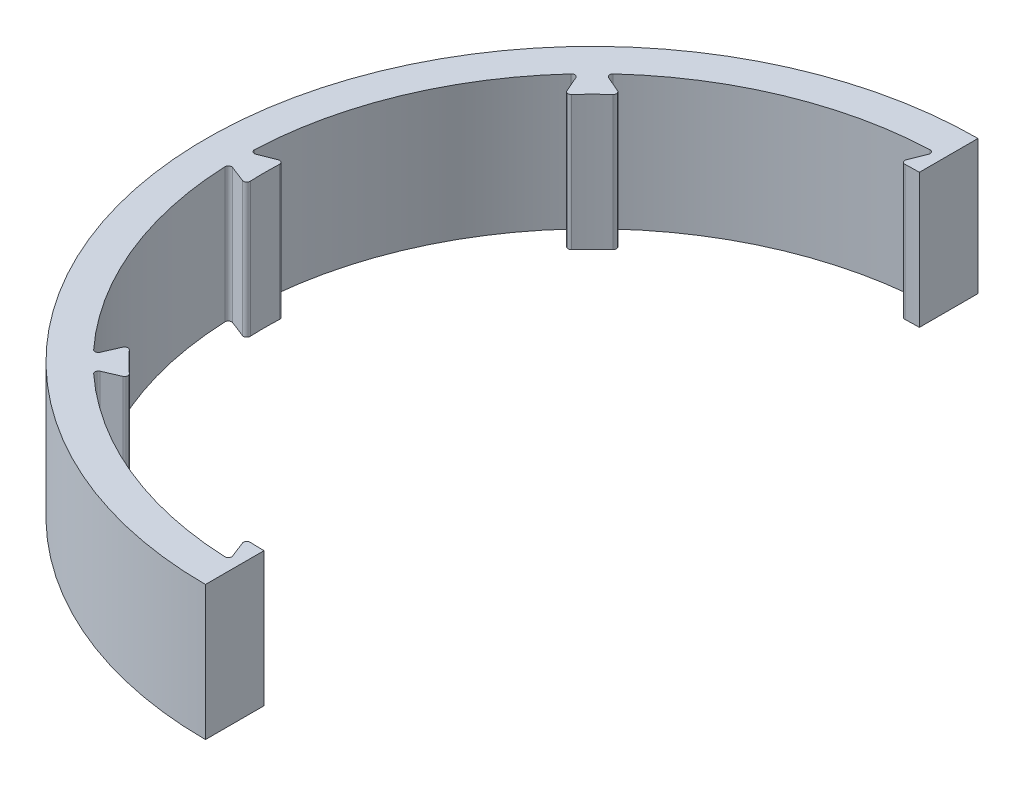
from build123d import *

# Parameters (mm, degrees)
SKETCH1_R                = 115
SKETCH1_R_2              = 105.05
BOSS_EXTRUDE1_DEPTH      = 40
BOSS_EXTRUDE2_DEPTH      = 40
FILLET2_R                = 1
CIRPATTERN2_COUNT        = 8
FILLET2_OF_CIRPATTERN2_R = 1
CUT_EXTRUDE2_DEPTH       = 41


with BuildPart() as part:
    # Sketch1 → Boss-Extrude1 (new body)
    with BuildSketch(Plane(origin=(0, 0, 0), x_dir=(1, 0, 0), z_dir=(0, 1, 0))):
        Circle(SKETCH1_R)
        Circle(SKETCH1_R_2, mode=Mode.SUBTRACT)
    extrude(amount=BOSS_EXTRUDE1_DEPTH)

    # Sketch2 → Boss-Extrude2 (add, through all)
    with BuildSketch(Plane(origin=(0, 40, 0), x_dir=(1, 0, 0), z_dir=(0, 1, 0))):
        with BuildLine():
            ThreePointArc((2.891374007, 105.010201678), (0, 105.05), (-2.891374007, 105.010201678))
            Line((-2.891374007, 105.010201678), (-5.889932008, 97.372024735))
            ThreePointArc((-5.889932008, 97.372024735), (0, 97.55), (5.889932008, 97.372024735))
            Line((5.889932008, 97.372024735), (2.891374007, 105.010201678))
        make_face()
    boss_extrude2 = extrude(amount=-BOSS_EXTRUDE2_DEPTH)

    # Fillet2
    fillet2_edges = [part.edges().sort_by_distance(p)[0] for p in [
        (5.889932008, 20, -97.372024735),
        (-5.889932008, 20, -97.372024735),
        (-2.891374007, 20, -105.010201678),
        (2.891374007, 20, -105.010201678),
    ]]
    fillet(fillet2_edges, radius=FILLET2_R)

    # CirPattern2: Boss-Extrude2 ×8 about axis
    cirpattern2_axis = Axis((0, 0, 0), (0, 1, 0))
    for i in range(1, CIRPATTERN2_COUNT):
        add(boss_extrude2.rotate(cirpattern2_axis, i * 360 / CIRPATTERN2_COUNT))

    # Fillet2 of CirPattern2
    fillet2_of_cirpattern2_edges = [part.edges().sort_by_distance(p)[0] for p in [
        (-64.687608124, 20, -73.017229852),
        (-73.017229852, 20, -64.687608124),
        (-76.297935867, 20, -72.208915532),
        (-72.208915532, 20, -76.297935867),
        (-97.372024735, 20, -5.889932008),
        (-97.372024735, 20, 5.889932008),
        (-105.010201678, 20, 2.891374007),
        (-105.010201678, 20, -2.891374007),
        (-73.017229852, 20, 64.687608124),
        (-64.687608124, 20, 73.017229852),
        (-72.208915532, 20, 76.297935867),
        (-76.297935867, 20, 72.208915532),
        (-5.889932008, 20, 97.372024735),
        (5.889932008, 20, 97.372024735),
        (2.891374007, 20, 105.010201678),
        (-2.891374007, 20, 105.010201678),
        (64.687608124, 20, 73.017229852),
        (73.017229852, 20, 64.687608124),
        (76.297935867, 20, 72.208915532),
        (72.208915532, 20, 76.297935867),
        (97.372024735, 20, 5.889932008),
        (97.372024735, 20, -5.889932008),
        (105.010201678, 20, -2.891374007),
        (105.010201678, 20, 2.891374007),
        (73.017229852, 20, -64.687608124),
        (64.687608124, 20, -73.017229852),
        (72.208915532, 20, -76.297935867),
        (76.297935867, 20, -72.208915532),
    ]]
    fillet(fillet2_of_cirpattern2_edges, radius=FILLET2_OF_CIRPATTERN2_R)

    # Sketch3 → Cut-Extrude2 (cut, through all)
    with BuildSketch(Plane(origin=(0, 40, 0), x_dir=(1, 0, 0), z_dir=(0, 1, 0))):
        with BuildLine():
            Line((-0.15, 117.349449893), (-0.15, -117.349449893))
            ThreePointArc((-0.15, -117.349449893), (82.828591788, -82.978591788), (117.199449893, 0))
            ThreePointArc((117.199449893, 0), (82.828591788, 82.978591788), (-0.15, 117.349449893))
        make_face()
    extrude(amount=-CUT_EXTRUDE2_DEPTH, mode=Mode.SUBTRACT)


solid = part.part
